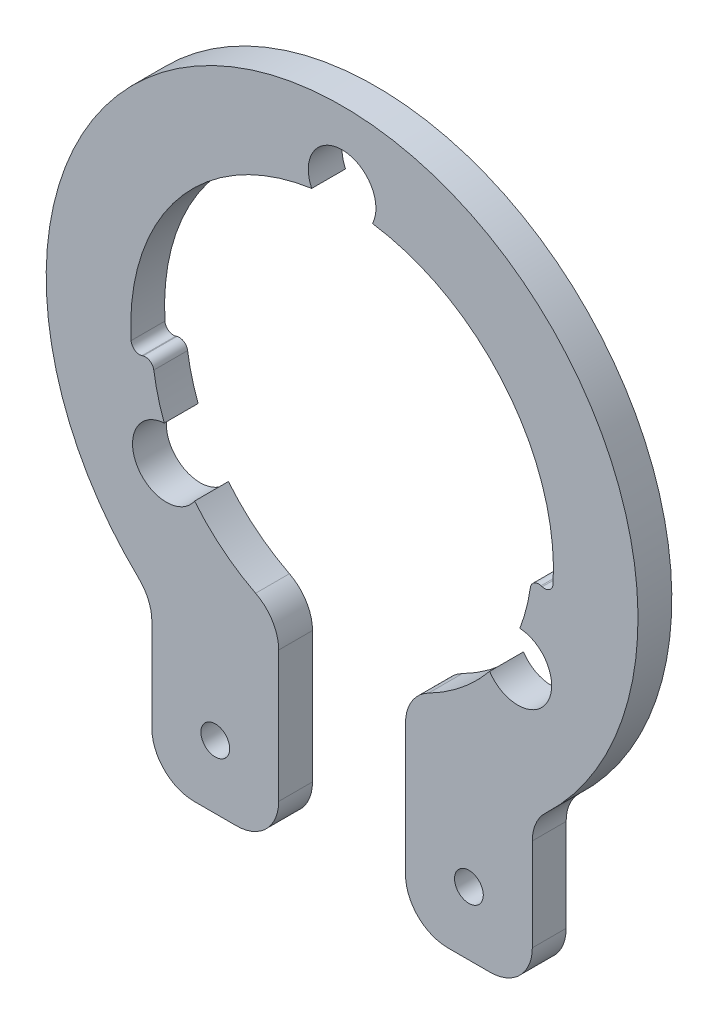
from build123d import *

# Parameters (mm, degrees)
BOSS_EXTRUDE1_DEPTH = 4
SKETCH2_R           = 4
CUT_EXTRUDE2_DEPTH  = 5
SKETCH5_R           = 1.7
CUT_EXTRUDE3_DEPTH  = 5
FILLET1_R           = 5
FILLET2_R           = 5
FILLET3_R           = 1


with BuildPart() as part:
    # Sketch3 → Boss-Extrude1 (new body)
    with BuildSketch(Plane.XY):
        with BuildLine():
            Line((-7.5, -21.213203436), (-7.5, -45))
            Line((-7.5, -45), (-22.5, -45))
            Line((-22.5, -45), (-22.5, -26.809513237))
            ThreePointArc((-22.5, -26.809513237), (0, 35), (22.5, -26.809513237))
            Line((22.5, -26.809513237), (22.5, -45))
            Line((22.5, -45), (7.5, -45))
            Line((7.5, -45), (7.5, -21.213203436))
            ThreePointArc((7.5, -21.213203436), (17.734611105, -13.846789121), (22.398843942, -2.131147595))
            ThreePointArc((22.398843942, -2.131147595), (23.640685275, -2.41653339), (24.836154938, -2.857517782))
            ThreePointArc((24.836154938, -2.857517782), (0, 25), (-24.836154938, -2.857517782))
            ThreePointArc((-24.836154938, -2.857517782), (-23.640685275, -2.41653339), (-22.398843942, -2.131147595))
            ThreePointArc((-22.398843942, -2.131147595), (-17.734611105, -13.846789121), (-7.5, -21.213203436))
        make_face()
    extrude(amount=BOSS_EXTRUDE1_DEPTH)

    # Sketch2 → Cut-Extrude2 (cut, through all)
    with BuildSketch(Plane.XY):
        with Locations((0, 26.5)):
            Circle(SKETCH2_R)
        with Locations((-20.784609691, -12)):
            Circle(SKETCH2_R)
        with Locations((20.784609691, -12)):
            Circle(SKETCH2_R)
    extrude(amount=CUT_EXTRUDE2_DEPTH, mode=Mode.SUBTRACT)

    # Sketch5 → Cut-Extrude3 (cut, through all)
    with BuildSketch(Plane.XY):
        with Locations((-15, -37.5)):
            Circle(SKETCH5_R)
        with Locations((15, -37.5)):
            Circle(SKETCH5_R)
    extrude(amount=CUT_EXTRUDE3_DEPTH, mode=Mode.SUBTRACT)

    # Fillet1
    fillet1_edges = [part.edges().sort_by_distance(p)[0] for p in [
        (22.5, -45, 2),
        (-22.5, -45, 2),
    ]]
    fillet(fillet1_edges, radius=FILLET1_R)

    # Fillet2
    fillet2_edges = [part.edges().sort_by_distance(p)[0] for p in [
        (22.5, -26.809513237, 2),
        (7.5, -45, 2),
        (7.5, -21.213203436, 2),
        (-7.5, -21.213203436, 2),
        (-7.5, -45, 2),
        (-22.5, -26.809513237, 2),
    ]]
    fillet(fillet2_edges, radius=FILLET2_R)

    # Fillet3
    fillet3_edges = [part.edges().sort_by_distance(p)[0] for p in [
        (22.398843942, -2.131147595, 2),
        (24.836154938, -2.857517782, 2),
        (-24.836154938, -2.857517782, 2),
        (-22.398843942, -2.131147595, 2),
    ]]
    fillet(fillet3_edges, radius=FILLET3_R)


solid = part.part
